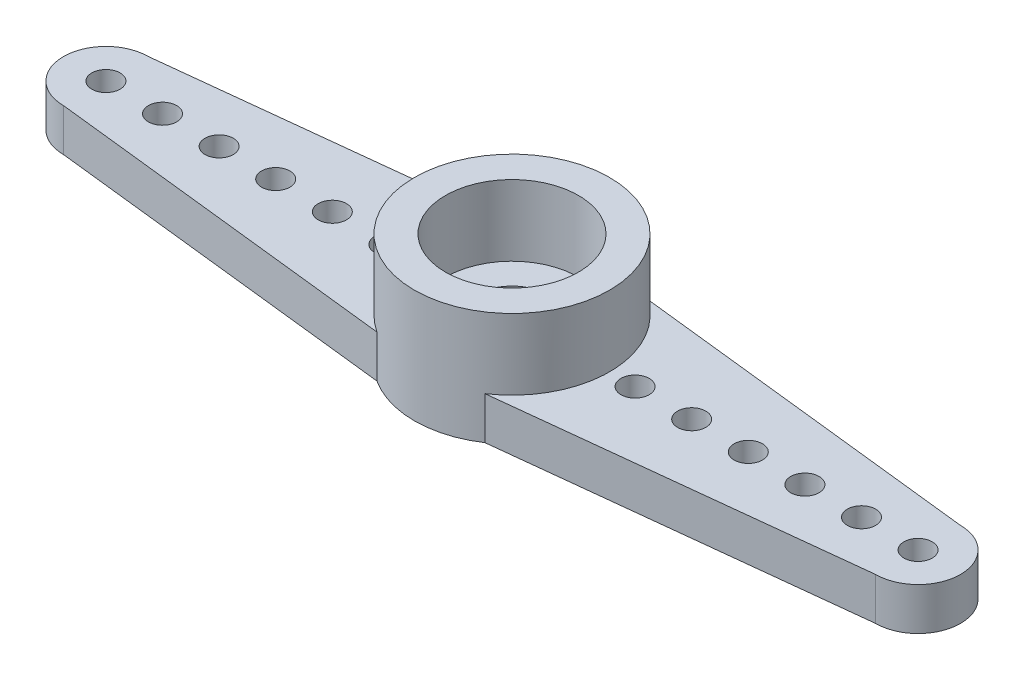
from build123d import *

# Parameters (mm, degrees)
SKETCH2_R           = 2.35
SKETCH2_R_2         = 1.275
BOSS_EXTRUDE3_DEPTH = 0.5
SKETCH2_7_R         = 3.45
SKETCH2_7_R_2       = 2.35
BOSS_EXTRUDE5_DEPTH = 2.5
BOSS_EXTRUDE6_START = 1.5
SKETCH1_R           = 2.35
SKETCH1_R_2         = 0.5
BOSS_EXTRUDE6_DEPTH = 1.5


with BuildPart() as part:
    # Sketch2 → Boss-Extrude3 (new body)
    with BuildSketch(Plane(origin=(0, 1.5, 0), x_dir=(1, 0, 0), z_dir=(0, 1, 0))):
        Circle(SKETCH2_R)
        Circle(SKETCH2_R_2, mode=Mode.SUBTRACT)
    extrude(amount=-BOSS_EXTRUDE3_DEPTH)



with BuildPart() as body_2:
    # Sketch2_7 → Boss-Extrude5 (new body)
    with BuildSketch(Plane(origin=(0, 1.5, 0), x_dir=(1, 0, 0), z_dir=(0, 1, 0))):
        Circle(SKETCH2_7_R)
        Circle(SKETCH2_7_R_2, mode=Mode.SUBTRACT)
    extrude(amount=BOSS_EXTRUDE5_DEPTH)


with BuildPart() as part_1:
    add(part.part)

    add(body_2.part)  # Boss-Extrude6 merges body 2
    # Sketch1 → Boss-Extrude6 (add)
    with BuildSketch(Plane(origin=(0, 0, 0), x_dir=(1, 0, 0), z_dir=(0, 1, 0)).offset(BOSS_EXTRUDE6_START)):
        with BuildLine():
            Line((14.35, 1.5), (1.879742768, 2.892933999))
            ThreePointArc((1.879742768, 2.892933999), (-0.020024107, 3.449941889), (-1.913197247, 2.870919068))
            Line((-1.913197247, 2.870919068), (-14.35, 1.5))
            ThreePointArc((-14.35, 1.5), (-15.85, 0), (-14.35, -1.5))
            Line((-14.35, -1.5), (-1.879742768, -2.892933999))
            ThreePointArc((-1.879742768, -2.892933999), (0.020024107, -3.449941889), (1.913197247, -2.870919068))
            Line((1.913197247, -2.870919068), (14.35, -1.5))
            ThreePointArc((14.35, -1.5), (15.85, 0), (14.35, 1.5))
        make_face()
        Circle(SKETCH1_R, mode=Mode.SUBTRACT)
        with Locations((12.35, 0)):
            Circle(SKETCH1_R_2, mode=Mode.SUBTRACT)
        with Locations((14.35, 0)):
            Circle(SKETCH1_R_2, mode=Mode.SUBTRACT)
        with Locations((10.35, 0)):
            Circle(SKETCH1_R_2, mode=Mode.SUBTRACT)
        with Locations((8.35, 0)):
            Circle(SKETCH1_R_2, mode=Mode.SUBTRACT)
        with Locations((6.35, 0)):
            Circle(SKETCH1_R_2, mode=Mode.SUBTRACT)
        with Locations((4.35, 0)):
            Circle(SKETCH1_R_2, mode=Mode.SUBTRACT)
        with Locations((-12.35, 0)):
            Circle(SKETCH1_R_2, mode=Mode.SUBTRACT)
        with Locations((-14.35, 0)):
            Circle(SKETCH1_R_2, mode=Mode.SUBTRACT)
        with Locations((-10.35, 0)):
            Circle(SKETCH1_R_2, mode=Mode.SUBTRACT)
        with Locations((-8.35, 0)):
            Circle(SKETCH1_R_2, mode=Mode.SUBTRACT)
        with Locations((-6.35, 0)):
            Circle(SKETCH1_R_2, mode=Mode.SUBTRACT)
        with Locations((-4.35, 0)):
            Circle(SKETCH1_R_2, mode=Mode.SUBTRACT)
    extrude(amount=-BOSS_EXTRUDE6_DEPTH)


solid = part_1.part
